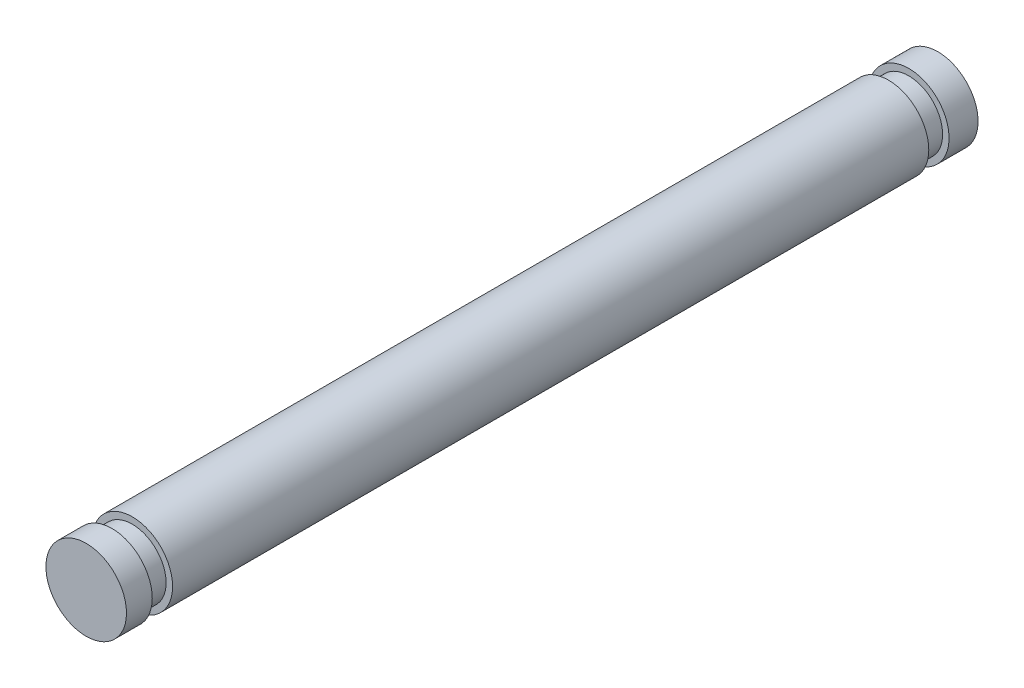
from build123d import *

# Parameters (mm, degrees)
SKETCH1_R           = 3.175
BOSS_EXTRUDE1_DEPTH = 59.6138
SKETCH2_R           = 2.667
BOSS_EXTRUDE2_DEPTH = 1.6002
SKETCH3_R           = 3.175
BOSS_EXTRUDE3_DEPTH = 2.286
SKETCH4_R           = 2.667
BOSS_EXTRUDE4_DEPTH = 1.6002
SKETCH5_R           = 3.175
BOSS_EXTRUDE5_DEPTH = 2.032


with BuildPart() as part:
    # Sketch1 → Boss-Extrude1 (new body)
    with BuildSketch(Plane.XY):
        Circle(SKETCH1_R)
    extrude(amount=BOSS_EXTRUDE1_DEPTH)

    # Sketch2 → Boss-Extrude2 (add)
    with BuildSketch(Plane(origin=(0, 0, 0), x_dir=(-1, 0, 0), z_dir=(0, 0, -1))):
        Circle(SKETCH2_R)
    extrude(amount=BOSS_EXTRUDE2_DEPTH)

    # Sketch3 → Boss-Extrude3 (add)
    with BuildSketch(Plane(origin=(0, 0, -1.6002), x_dir=(-1, 0, 0), z_dir=(0, 0, -1))):
        Circle(SKETCH3_R)
    extrude(amount=BOSS_EXTRUDE3_DEPTH)

    # Sketch4 → Boss-Extrude4 (add)
    with BuildSketch(Plane.XY.offset(59.6138)):
        Circle(SKETCH4_R)
    extrude(amount=BOSS_EXTRUDE4_DEPTH)

    # Sketch5 → Boss-Extrude5 (add)
    with BuildSketch(Plane.XY.offset(61.214)):
        Circle(SKETCH5_R)
    extrude(amount=BOSS_EXTRUDE5_DEPTH)


solid = part.part
